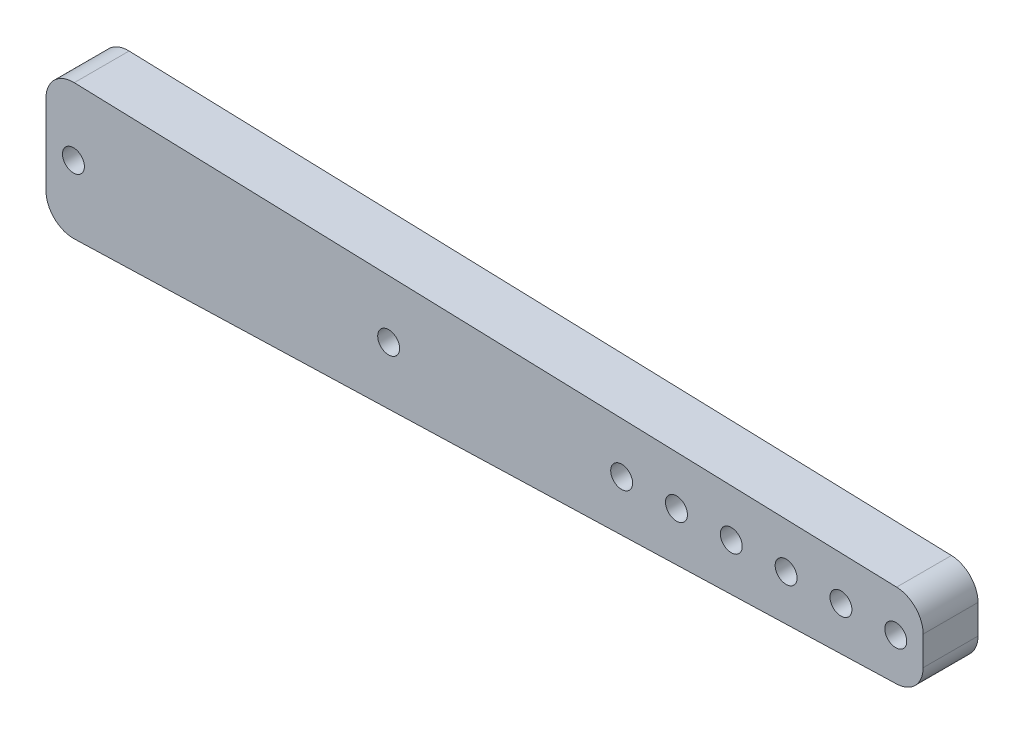
from build123d import *

# Parameters (mm, degrees)
BOSS_EXTRUDE1_DEPTH = 6.35
SKETCH2_R           = 1.27
CUT_EXTRUDE1_DEPTH  = 7.35
LPATTERN1_COUNT     = 6
LPATTERN1_PITCH     = 6.35
SKETCH4_R           = 1.27
CUT_EXTRUDE2_DEPTH  = 7.35
FILLET1_R           = 3.175


with BuildPart() as part:
    # Sketch1 → Boss-Extrude1 (new body)
    with BuildSketch(Plane.XY):
        Polygon((0, 0), (101.6, 3.175), (101.6, 12.7), (0, 15.875), align=None)
    extrude(amount=BOSS_EXTRUDE1_DEPTH)

    # Sketch2 → Cut-Extrude1 (cut, through all)
    with BuildSketch(Plane.XY.offset(6.35)):
        with Locations((98.425, 7.9375)):
            Circle(SKETCH2_R)
    cut_extrude1 = extrude(amount=-CUT_EXTRUDE1_DEPTH, mode=Mode.SUBTRACT)

    # LPattern1: Cut-Extrude1 ×6
    with Locations(*[(-i * LPATTERN1_PITCH, 0, 0) for i in range(1, LPATTERN1_COUNT)]):
        add(cut_extrude1, mode=Mode.SUBTRACT)

    # Sketch4 → Cut-Extrude2 (cut, through all)
    with BuildSketch(Plane.XY.offset(6.35)):
        with Locations((3.175, 7.9375)):
            Circle(SKETCH4_R)
        with Locations((39.6875, 7.9375)):
            Circle(SKETCH4_R)
    extrude(amount=-CUT_EXTRUDE2_DEPTH, mode=Mode.SUBTRACT)

    # Fillet1
    fillet1_edges = [part.edges().sort_by_distance(p)[0] for p in [
        (0, 15.875, 3.175),
        (101.6, 12.7, 3.175),
        (101.6, 3.175, 3.175),
        (0, 0, 3.175),
    ]]
    fillet(fillet1_edges, radius=FILLET1_R)


solid = part.part
